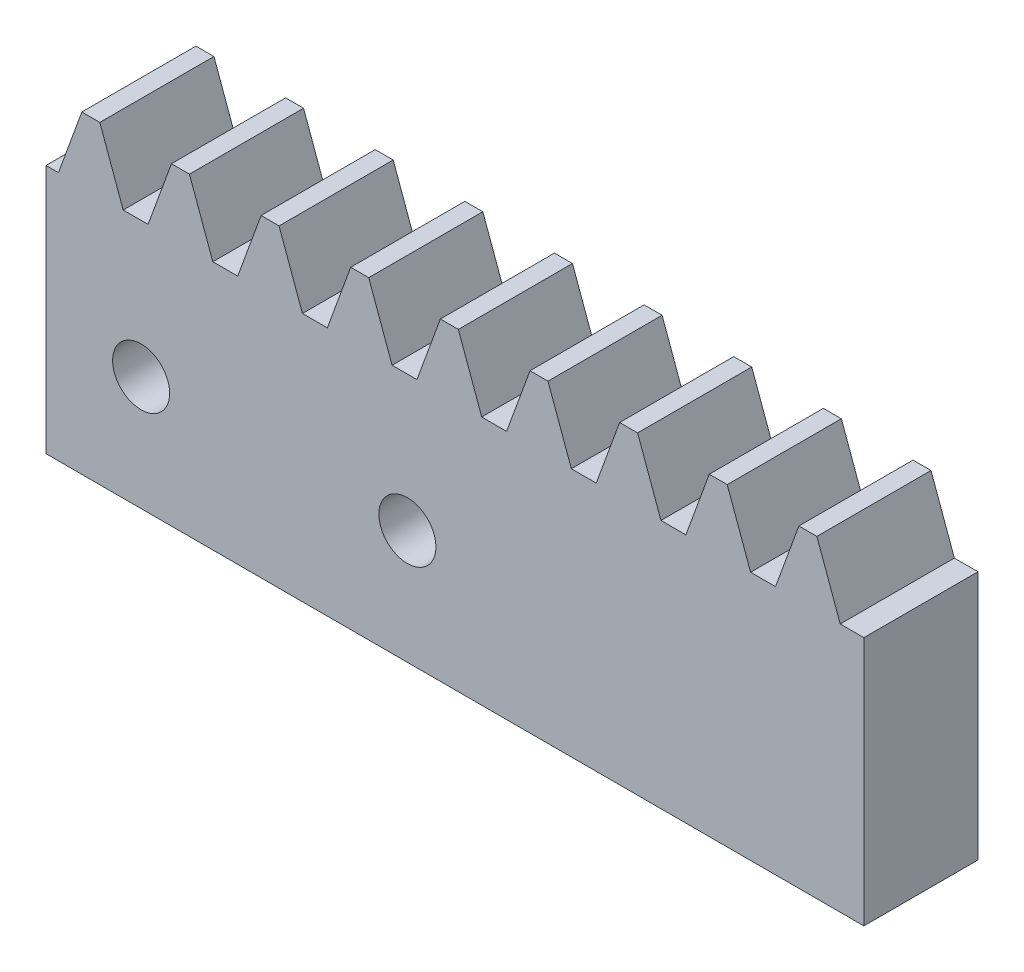
from build123d import *

# Parameters (mm, degrees)
BLANKSKE_W              = 43
BLANKSKE_H              = 16.5
BLANK_DEPTH             = 6
TOOTHCUTSIM_DEPTH       = 47.446205442
TEETHCUTS_COUNT         = 10
TEETHCUTS_PITCH         = 4.712388975
ESQUISSE1_R             = 1.5
ENL_V_MAT_EXTRU_1_DEPTH = 6


with BuildPart() as part:
    # BlankSke → Blank (new body)
    with BuildSketch(Plane.XY):
        with Locations((21.5, 8.25)):
            Rectangle(BLANKSKE_W, BLANKSKE_H)
    extrude(amount=-BLANK_DEPTH)

    # TooCutSkeSim → ToothCutSim (cut, through all)
    with BuildSketch(Plane.XY):
        Polygon((0.654653055, 13.125), (-0.654653055, 13.125), (-1.892297439, 16.5254), (1.892297439, 16.5254), align=None)
    toothcutsim = extrude(amount=-TOOTHCUTSIM_DEPTH, mode=Mode.SUBTRACT)

    # TeethCuts: ToothCutSim ×10
    with Locations(*[(i * TEETHCUTS_PITCH, 0, 0) for i in range(1, TEETHCUTS_COUNT)]):
        add(toothcutsim, mode=Mode.SUBTRACT)

    # Esquisse1 → Enlèv. mat.-Extru.1 (cut)
    with BuildSketch(Plane.XY):
        with Locations((5, 6)):
            Circle(ESQUISSE1_R)
        with Locations((19, 6)):
            Circle(ESQUISSE1_R)
    extrude(amount=-ENL_V_MAT_EXTRU_1_DEPTH, mode=Mode.SUBTRACT)


solid = part.part
